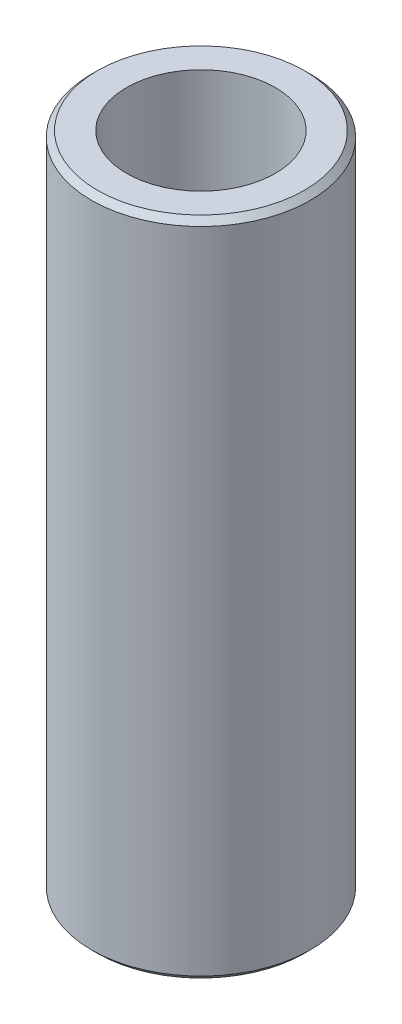
from build123d import *

# Parameters (mm, degrees)
SKETCH1_R           = 4.7625
BOSS_EXTRUDE1_DEPTH = 14.381250003
CHAMFER1_SIZE       = 0.254
SKETCH2_R           = 3.2385
CUT_EXTRUDE1_DEPTH  = 29.762500006


with BuildPart() as part:
    # Sketch1 → Boss-Extrude1 (new body, symmetric)
    with BuildSketch(Plane(origin=(0, 0, 0), x_dir=(1, 0, 0), z_dir=(0, 1, 0))):
        Circle(SKETCH1_R)
    extrude(amount=BOSS_EXTRUDE1_DEPTH, both=True)

    # Chamfer1
    chamfer1_edges = [part.edges().sort_by_distance(p)[0] for p in [
        (-4.7625, -14.381250003, 0),
        (-4.7625, 14.381250003, 0),
    ]]
    chamfer(chamfer1_edges, length=CHAMFER1_SIZE)

    # Sketch2 → Cut-Extrude1 (cut, through all)
    with BuildSketch(Plane.XZ.offset(14.381250003)):
        Circle(SKETCH2_R)
    extrude(amount=-CUT_EXTRUDE1_DEPTH, mode=Mode.SUBTRACT)


solid = part.part
